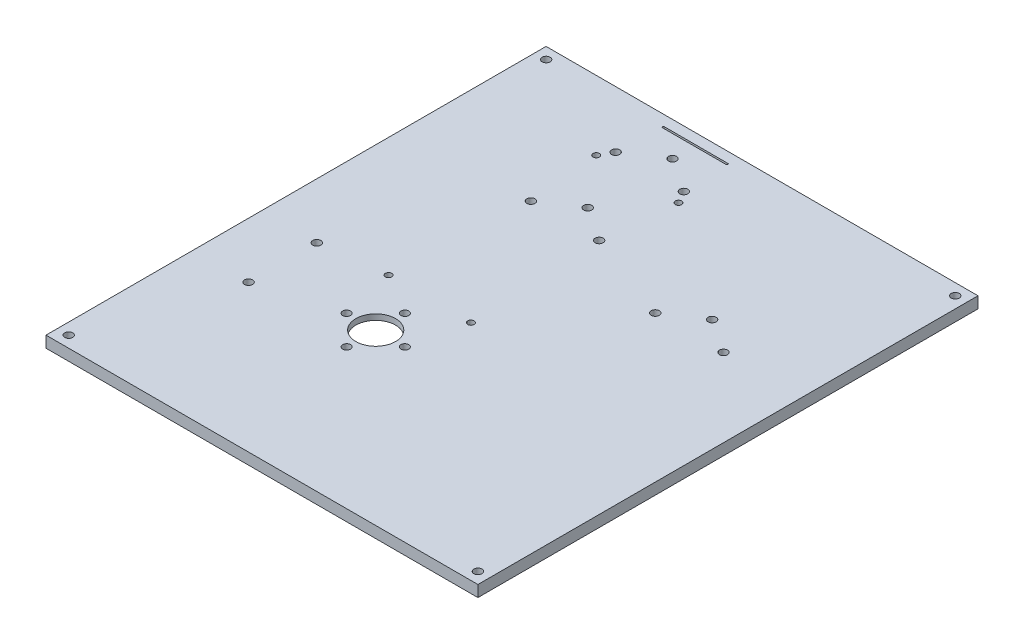
from build123d import *

# Parameters (mm, degrees)
SKETCH1_W             = 101.6
SKETCH1_H             = 101.6
BOSS_EXTRUDE1_DEPTH   = 3.175
SKETCH3_W             = 50.8
SKETCH3_H             = 101.6
BOSS_EXTRUDE2_DEPTH   = 3.175
SKETCH6_W             = 152.4
SKETCH6_H             = 38.1
BOSS_EXTRUDE4_DEPTH   = 3.175
SKETCH9_W             = 6.35
SKETCH9_H             = 139.7
BOSS_EXTRUDE5_DEPTH   = 3.175
SKETCH7_OUTSIDE_W     = 203.048
SKETCH7_OUTSIDE_H     = 183.998
SKETCH7_OUTSIDE_W_2   = 120.65
SKETCH7_OUTSIDE_H_2   = 139.7
CUT_EXTRUDE3_DEPTH    = 4.175
F_4_40_TAPPED_HOLE2_D = 2.2606
SKETCH15_R            = 2.38125
CUT_EXTRUDE5_DEPTH    = 1.5875
FILLET1_R             = 3.429
F_2_56_TAPPED_HOLE_D  = 1.778
SKETCH19_R            = 2.4765
SKETCH19_R_2          = 0.889
BOSS_EXTRUDE6_DEPTH   = 1.5875
SKETCH21_R            = 5.55
CUT_EXTRUDE7_DEPTH    = 4.175
CUT_EXTRUDE8_DEPTH    = 2.5875
M2_CLEARANCE_HOLE1_D  = 2.2


with BuildPart() as part:
    # Sketch1 → Boss-Extrude1 (new body)
    with BuildSketch(Plane(origin=(0, 0, 0), x_dir=(1, 0, 0), z_dir=(0, 1, 0))):
        Rectangle(SKETCH1_W, SKETCH1_H)
    extrude(amount=BOSS_EXTRUDE1_DEPTH)

    # Sketch3 → Boss-Extrude2 (add)
    with BuildSketch(Plane(origin=(0, 3.175, 0), x_dir=(1, 0, 0), z_dir=(0, 1, 0))):
        with Locations((76.2, 0)):
            Rectangle(SKETCH3_W, SKETCH3_H)
    extrude(amount=-BOSS_EXTRUDE2_DEPTH)

    # Sketch6 → Boss-Extrude4 (add)
    with BuildSketch(Plane(origin=(0, 3.175, 0), x_dir=(1, 0, 0), z_dir=(0, 1, 0))):
        with Locations((25.4, 69.85)):
            Rectangle(SKETCH6_W, SKETCH6_H)
    extrude(amount=-BOSS_EXTRUDE4_DEPTH)

    # Sketch9 → Boss-Extrude5 (add)
    with BuildSketch(Plane(origin=(0, 3.175, 0), x_dir=(1, 0, 0), z_dir=(0, 1, 0))):
        with Locations((-53.975, 19.05)):
            Rectangle(SKETCH9_W, SKETCH9_H)
    extrude(amount=-BOSS_EXTRUDE5_DEPTH)

    # Sketch7 outside → Cut-Extrude3 (cut, through all)
    with BuildSketch(Plane(origin=(0, 3.175, 0), x_dir=(1, 0, 0), z_dir=(0, 1, 0))):
        with Locations((22.225, 19.05)):
            Rectangle(SKETCH7_OUTSIDE_W, SKETCH7_OUTSIDE_H)
        with Locations((3.175, 19.05)):
            Rectangle(SKETCH7_OUTSIDE_W_2, SKETCH7_OUTSIDE_H_2, mode=Mode.SUBTRACT)
    extrude(amount=-CUT_EXTRUDE3_DEPTH, mode=Mode.SUBTRACT)

    # #4-40 Tapped Hole2 (through all)
    with Locations(Plane(origin=(0, 3.175, 0), x_dir=(1, 0, 0), z_dir=(0, 1, 0))):
        with Locations((32.130819486, 46.000976371), (-2.794180514, 49.350976371), (-12.319180514, 55.700976371), (-21.844180514, 49.350976371), (22.605819486, 39.650976371), (41.655819486, 39.650976371), (-41.662637498, 9.355925684), (-41.662637498, -9.694074316), (-2.794180514, 73.025), (-12.319180514, 79.375), (-21.844180514, 73.025), (60.325, -47.625), (-53.975, -47.625), (60.325, 85.725), (-53.975, 85.725)):
            Hole(F_4_40_TAPPED_HOLE2_D / 2)

    # Sketch15 → Cut-Extrude5 (cut)
    with BuildSketch(Plane.XZ):
        with BuildLine():
            Line((-52.200121043, -87.3125), (58.550121043, -87.3125))
            ThreePointArc((58.550121043, -87.3125), (58.641201977, -84.041201977), (61.9125, -83.950121043))
            Line((61.9125, -83.950121043), (61.9125, 45.850121043))
            ThreePointArc((61.9125, 45.850121043), (58.641201977, 45.941201977), (58.550121043, 49.2125))
            Line((58.550121043, 49.2125), (-52.200121043, 49.2125))
            ThreePointArc((-52.200121043, 49.2125), (-52.291201977, 45.941201977), (-55.5625, 45.850121043))
            Line((-55.5625, 45.850121043), (-55.5625, -83.950121043))
            ThreePointArc((-55.5625, -83.950121043), (-52.291201977, -84.041201977), (-52.200121043, -87.3125))
        make_face()
        with Locations((32.130819486, -46.000976371)):
            Circle(SKETCH15_R, mode=Mode.SUBTRACT)
        with Locations((-2.794180514, -49.350976371)):
            Circle(SKETCH15_R, mode=Mode.SUBTRACT)
        with Locations((-12.319180514, -55.700976371)):
            Circle(SKETCH15_R, mode=Mode.SUBTRACT)
        with Locations((-21.844180514, -49.350976371)):
            Circle(SKETCH15_R, mode=Mode.SUBTRACT)
        with Locations((41.655819486, -39.650976371)):
            Circle(SKETCH15_R, mode=Mode.SUBTRACT)
        with Locations((22.605819486, -39.650976371)):
            Circle(SKETCH15_R, mode=Mode.SUBTRACT)
        with Locations((-41.662637498, 9.694074316)):
            Circle(SKETCH15_R, mode=Mode.SUBTRACT)
        with Locations((-41.662637498, -9.355925684)):
            Circle(SKETCH15_R, mode=Mode.SUBTRACT)
        with Locations((-2.794180514, -73.025)):
            Circle(SKETCH15_R, mode=Mode.SUBTRACT)
        with Locations((-12.319180514, -79.375)):
            Circle(SKETCH15_R, mode=Mode.SUBTRACT)
        with Locations((-21.844180514, -73.025)):
            Circle(SKETCH15_R, mode=Mode.SUBTRACT)
    extrude(amount=-CUT_EXTRUDE5_DEPTH, mode=Mode.SUBTRACT)

    # Fillet1
    fillet1_edges = [part.edges().sort_by_distance(p)[0] for p in [
        (-52.200121043, 0.79375, -87.3125),
        (-55.5625, 0.79375, -83.950121043),
        (-55.5625, 0.79375, 45.850121043),
        (-52.200121043, 0.79375, 49.2125),
        (58.550121043, 0.79375, 49.2125),
        (61.9125, 0.79375, 45.850121043),
        (61.9125, 0.79375, -83.950121043),
        (58.550121043, 0.79375, -87.3125),
    ]]
    fillet(fillet1_edges, radius=FILLET1_R)

    # #2-56 Tapped Hole (through all)
    with Locations(Plane(origin=(0, 3.175, 0), x_dir=(1, 0, 0), z_dir=(0, 1, 0))):
        with Locations((-0.819180486, 11.557600033), (-23.819180486, 11.557600033), (-0.819180486, 69.557600033), (-23.819180486, 69.557600033)):
            Hole(F_2_56_TAPPED_HOLE_D / 2)

    # Sketch19 → Boss-Extrude6 (add)
    with BuildSketch(Plane(origin=(0, 1.5875, 0), x_dir=(1, 0, 0), z_dir=(0, 1, 0))):
        with Locations((-23.819180486, 69.557600033)):
            Circle(SKETCH19_R)
        with Locations((-23.819180486, 69.557600033)):
            Circle(SKETCH19_R_2, mode=Mode.SUBTRACT)
        with Locations((-0.819180486, 69.557600033)):
            Circle(SKETCH19_R)
        with Locations((-0.819180486, 69.557600033)):
            Circle(SKETCH19_R_2, mode=Mode.SUBTRACT)
        with Locations((-23.819180486, 11.557600033)):
            Circle(SKETCH19_R)
        with Locations((-23.819180486, 11.557600033)):
            Circle(SKETCH19_R_2, mode=Mode.SUBTRACT)
        with Locations((-0.819180486, 11.557600033)):
            Circle(SKETCH19_R)
        with Locations((-0.819180486, 11.557600033)):
            Circle(SKETCH19_R_2, mode=Mode.SUBTRACT)
    extrude(amount=-BOSS_EXTRUDE6_DEPTH)

    # Sketch21 → Cut-Extrude7 (cut, through all)
    with BuildSketch(Plane(origin=(0, 3.175, 0), x_dir=(1, 0, 0), z_dir=(0, 1, 0))):
        with Locations((-12.319180514, -3.524023629)):
            Circle(SKETCH21_R)
    extrude(amount=-CUT_EXTRUDE7_DEPTH, mode=Mode.SUBTRACT)

    # Sketch22 → Cut-Extrude8 (cut, through all)
    with BuildSketch(Plane.XZ.offset(-1.5875)):
        with BuildLine():
            Line((-21.209180514, -85.471), (-3.429180514, -85.471))
            ThreePointArc((-3.429180514, -85.471), (-3.175180514, -85.725), (-3.429180514, -85.979))
            Line((-3.429180514, -85.979), (-21.209180514, -85.979))
            ThreePointArc((-21.209180514, -85.979), (-21.463180514, -85.725), (-21.209180514, -85.471))
        make_face()
    extrude(amount=-CUT_EXTRUDE8_DEPTH, mode=Mode.SUBTRACT)

    # M2 Clearance Hole1 (through all)
    with Locations(Plane(origin=(0, 3.175, 0), x_dir=(1, 0, 0), z_dir=(0, 1, 0))):
        with Locations((-20.450908498, -3.524023629), (-12.319180514, -11.655751612), (-4.187452531, -3.524023629), (-12.319180514, 4.607704355)):
            Hole(M2_CLEARANCE_HOLE1_D / 2)


solid = part.part
